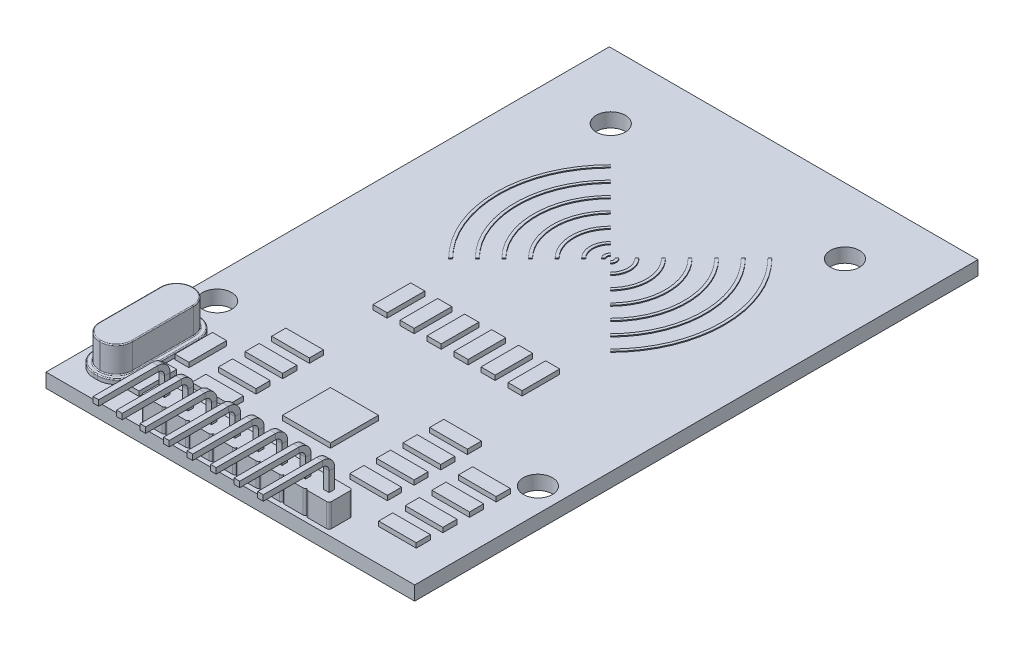
from build123d import *

# Parameters (mm, degrees)
SKETCH1_W                = 39.2
SKETCH1_H                = 59.9
BOSS_EXTRUDE1_DEPTH      = 1.5
SKETCH3_R                = 1.55
CUT_EXTRUDE1_DEPTH       = 1.5
BOSS_EXTRUDE3_DEPTH      = 2.5
SKETCH5_W                = 0.6
SKETCH5_H                = 0.6
CUT_EXTRUDE2_DEPTH       = 4
SKETCH6_W                = 0.6
SKETCH6_H                = 0.6
BOSS_EXTRUDE4_DEPTH      = 0.5
BOSS_EXTRUDE5_DEPTH      = 2.8
FILLET1_R                = 0.1
BOSS_EXTRUDE6_DEPTH      = 0.1
ESBO_O1_W                = 1.5
ESBO_O1_H                = 4
ESBO_O1_W_2              = 4
ESBO_O1_H_2              = 1.5
RESSALTO_EXTRUS_O1_DEPTH = 0.5
ESBO_O2_W                = 5.1
ESBO_O2_H                = 5.1
RESSALTO_EXTRUS_O2_DEPTH = 0.5


with BuildPart() as part:
    # Sketch1 → Boss-Extrude1 (new body)
    with BuildSketch(Plane(origin=(0, 0, 0), x_dir=(1, 0, 0), z_dir=(0, 1, 0))):
        Rectangle(SKETCH1_W, SKETCH1_H)
    extrude(amount=BOSS_EXTRUDE1_DEPTH)

    # Sketch3 → Cut-Extrude1 (cut)
    with BuildSketch(Plane(origin=(0, 1.5, 0), x_dir=(1, 0, 0), z_dir=(0, 1, 0))):
        with Locations((12.45, 22.95)):
            Circle(SKETCH3_R)
        with Locations((-12.45, 22.95)):
            Circle(SKETCH3_R)
        with Locations((17.05, -14.3)):
            Circle(SKETCH3_R)
        with Locations((-17.05, -14.3)):
            Circle(SKETCH3_R)
    extrude(amount=-CUT_EXTRUDE1_DEPTH, mode=Mode.SUBTRACT)

    # Sketch4 → Boss-Extrude3 (add)
    with BuildSketch(Plane(origin=(0, 1.5, 0), x_dir=(1, 0, 0), z_dir=(0, 1, 0))):
        with BuildLine():
            Line((-9.75, -26.95), (-7.75, -26.95))
            ThreePointArc((-7.75, -26.95), (-7.573223305, -27.023223305), (-7.5, -27.2))
            ThreePointArc((-7.5, -27.2), (-7.426776695, -27.023223305), (-7.25, -26.95))
            Line((-7.25, -26.95), (-5.25, -26.95))
            ThreePointArc((-5.25, -26.95), (-5.073223305, -27.023223305), (-5, -27.2))
            ThreePointArc((-5, -27.2), (-4.926776695, -27.023223305), (-4.75, -26.95))
            Line((-4.75, -26.95), (-2.75, -26.95))
            ThreePointArc((-2.75, -26.95), (-2.573223305, -27.023223305), (-2.5, -27.2))
            ThreePointArc((-2.5, -27.2), (-2.426776695, -27.023223305), (-2.25, -26.95))
            Line((-2.25, -26.95), (-0.25, -26.95))
            ThreePointArc((-0.25, -26.95), (-0.073223305, -27.023223305), (0, -27.2))
            ThreePointArc((0, -27.2), (0.073223305, -27.023223305), (0.25, -26.95))
            Line((0.25, -26.95), (2.25, -26.95))
            ThreePointArc((2.25, -26.95), (2.426776695, -27.023223305), (2.5, -27.2))
            ThreePointArc((2.5, -27.2), (2.573223305, -27.023223305), (2.75, -26.95))
            Line((2.75, -26.95), (4.75, -26.95))
            ThreePointArc((4.75, -26.95), (4.926776695, -27.023223305), (5, -27.2))
            ThreePointArc((5, -27.2), (5.073223305, -27.023223305), (5.25, -26.95))
            Line((5.25, -26.95), (7.25, -26.95))
            ThreePointArc((7.25, -26.95), (7.426776695, -27.023223305), (7.5, -27.2))
            ThreePointArc((7.5, -27.2), (7.573223305, -27.023223305), (7.75, -26.95))
            Line((7.75, -26.95), (9.75, -26.95))
            ThreePointArc((9.75, -26.95), (9.926776695, -27.023223305), (10, -27.2))
            Line((10, -27.2), (10, -29.2))
            ThreePointArc((10, -29.2), (9.926776695, -29.376776695), (9.75, -29.45))
            Line((9.75, -29.45), (7.75, -29.45))
            ThreePointArc((7.75, -29.45), (7.573223305, -29.376776695), (7.5, -29.2))
            ThreePointArc((7.5, -29.2), (7.426776695, -29.376776695), (7.25, -29.45))
            Line((7.25, -29.45), (5.25, -29.45))
            ThreePointArc((5.25, -29.45), (5.073223305, -29.376776695), (5, -29.2))
            ThreePointArc((5, -29.2), (4.926776695, -29.376776695), (4.75, -29.45))
            Line((4.75, -29.45), (2.75, -29.45))
            ThreePointArc((2.75, -29.45), (2.573223305, -29.376776695), (2.5, -29.2))
            ThreePointArc((2.5, -29.2), (2.426776695, -29.376776695), (2.25, -29.45))
            Line((2.25, -29.45), (0.25, -29.45))
            ThreePointArc((0.25, -29.45), (0.073223305, -29.376776695), (0, -29.2))
            ThreePointArc((0, -29.2), (-0.073223305, -29.376776695), (-0.25, -29.45))
            Line((-0.25, -29.45), (-2.25, -29.45))
            ThreePointArc((-2.25, -29.45), (-2.426776695, -29.376776695), (-2.5, -29.2))
            ThreePointArc((-2.5, -29.2), (-2.573223305, -29.376776695), (-2.75, -29.45))
            Line((-2.75, -29.45), (-4.75, -29.45))
            ThreePointArc((-4.75, -29.45), (-4.926776695, -29.376776695), (-5, -29.2))
            ThreePointArc((-5, -29.2), (-5.073223305, -29.376776695), (-5.25, -29.45))
            Line((-5.25, -29.45), (-7.25, -29.45))
            ThreePointArc((-7.25, -29.45), (-7.426776695, -29.376776695), (-7.5, -29.2))
            ThreePointArc((-7.5, -29.2), (-7.573223305, -29.376776695), (-7.75, -29.45))
            Line((-7.75, -29.45), (-9.75, -29.45))
            ThreePointArc((-9.75, -29.45), (-9.926776695, -29.376776695), (-10, -29.2))
            Line((-10, -29.2), (-10, -27.2))
            ThreePointArc((-10, -27.2), (-9.926776695, -27.023223305), (-9.75, -26.95))
        make_face()
    extrude(amount=BOSS_EXTRUDE3_DEPTH)

    # Sketch5 → Cut-Extrude2 (cut)
    with BuildSketch(Plane(origin=(0, 4, 0), x_dir=(1, 0, 0), z_dir=(0, 1, 0))):
        with Locations((-8.75, -28.2)):
            Rectangle(SKETCH5_W, SKETCH5_H)
        with Locations((-6.25, -28.2)):
            Rectangle(SKETCH5_W, SKETCH5_H)
        with Locations((-3.75, -28.2)):
            Rectangle(SKETCH5_W, SKETCH5_H)
        with Locations((-1.25, -28.2)):
            Rectangle(SKETCH5_W, SKETCH5_H)
        with Locations((1.25, -28.2)):
            Rectangle(SKETCH5_W, SKETCH5_H)
        with Locations((3.75, -28.2)):
            Rectangle(SKETCH5_W, SKETCH5_H)
        with Locations((6.25, -28.2)):
            Rectangle(SKETCH5_W, SKETCH5_H)
        with Locations((8.75, -28.2)):
            Rectangle(SKETCH5_W, SKETCH5_H)
    extrude(amount=-CUT_EXTRUDE2_DEPTH, mode=Mode.SUBTRACT)

    # Sweep1: sweep along a path in Sketch7
    with BuildLine(Plane.ZY.offset(10)) as sweep1_path:
        Line((28.2, -1), (28.2, 6))
        ThreePointArc((28.2, 6), (28.492893219, 6.707106781), (29.2, 7))
        Line((29.2, 7), (35.5, 7))
    # Sketch6 → Sweep1 (sweep)
    with BuildSketch(Plane(origin=(0, -1, 0), x_dir=(-1, 0, 0), z_dir=(0, -1, 0))):
        with Locations((6.25, -28.2)):
            Rectangle(SKETCH6_W, SKETCH6_H)
        with Locations((8.75, -28.2)):
            Rectangle(SKETCH6_W, SKETCH6_H)
        with Locations((3.75, -28.2)):
            Rectangle(SKETCH6_W, SKETCH6_H)
        with Locations((1.25, -28.2)):
            Rectangle(SKETCH6_W, SKETCH6_H)
        with Locations((-1.25, -28.2)):
            Rectangle(SKETCH6_W, SKETCH6_H)
        with Locations((-3.75, -28.2)):
            Rectangle(SKETCH6_W, SKETCH6_H)
        with Locations((-6.25, -28.2)):
            Rectangle(SKETCH6_W, SKETCH6_H)
        with Locations((-8.75, -28.2)):
            Rectangle(SKETCH6_W, SKETCH6_H)
    sweep(path=sweep1_path.line)

    # Sketch8 → Boss-Extrude4 (add)
    with BuildSketch(Plane(origin=(0, 1.5, 0), x_dir=(1, 0, 0), z_dir=(0, 1, 0))):
        with BuildLine():
            Line((-16.5, -17.15), (-16.15, -17.15))
            ThreePointArc((-16.15, -17.15), (-14.66507576, -17.76507576), (-14.05, -19.25))
            Line((-14.05, -19.25), (-14.05, -25.85))
            ThreePointArc((-14.05, -25.85), (-14.66507576, -27.33492424), (-16.15, -27.95))
            Line((-16.15, -27.95), (-16.5, -27.95))
            ThreePointArc((-16.5, -27.95), (-17.98492424, -27.33492424), (-18.6, -25.85))
            Line((-18.6, -25.85), (-18.6, -19.25))
            ThreePointArc((-18.6, -19.25), (-17.98492424, -17.76507576), (-16.5, -17.15))
        make_face()
    extrude(amount=BOSS_EXTRUDE4_DEPTH)

    # Sketch10 → Boss-Extrude5 (add)
    with BuildSketch(Plane(origin=(0, 2, 0), x_dir=(1, 0, 0), z_dir=(0, 1, 0))):
        with BuildLine():
            Line((-16.375, -17.6), (-16.275, -17.6))
            ThreePointArc((-16.275, -17.6), (-15.072918472, -18.097918472), (-14.575, -19.3))
            Line((-14.575, -19.3), (-14.575, -25.8))
            ThreePointArc((-14.575, -25.8), (-15.072918472, -27.002081528), (-16.275, -27.5))
            Line((-16.275, -27.5), (-16.375, -27.5))
            ThreePointArc((-16.375, -27.5), (-17.577081528, -27.002081528), (-18.075, -25.8))
            Line((-18.075, -25.8), (-18.075, -19.3))
            ThreePointArc((-18.075, -19.3), (-17.577081528, -18.097918472), (-16.375, -17.6))
        make_face()
    extrude(amount=BOSS_EXTRUDE5_DEPTH)

    # Fillet1
    fillet1_edges = [part.edges().sort_by_distance(p)[0] for p in [
        (-17.98492424, 2, 27.33492424),
        (-16.325, 2, 27.95),
        (-14.66507576, 2, 27.33492424),
        (-14.05, 2, 22.55),
        (-14.66507576, 2, 17.76507576),
        (-16.325, 2, 17.15),
        (-17.98492424, 2, 17.76507576),
        (-18.6, 2, 22.55),
        (-17.577081528, 2, 27.002081528),
        (-16.325, 2, 27.5),
        (-15.072918472, 2, 27.002081528),
        (-14.575, 2, 22.55),
        (-15.072918472, 2, 18.097918472),
        (-16.325, 2, 17.6),
        (-17.577081528, 2, 18.097918472),
        (-18.075, 2, 22.55),
        (-17.577081528, 4.8, 27.002081528),
        (-16.325, 4.8, 27.5),
        (-15.072918472, 4.8, 27.002081528),
        (-14.575, 4.8, 22.55),
        (-15.072918472, 4.8, 18.097918472),
        (-16.325, 4.8, 17.6),
        (-17.577081528, 4.8, 18.097918472),
        (-18.075, 4.8, 22.55),
    ]]
    fillet(fillet1_edges, radius=FILLET1_R)

    # Sketch11 → Boss-Extrude6 (add)
    with BuildSketch(Plane(origin=(0, 1.5, 0), x_dir=(1, 0, 0), z_dir=(0, 1, 0))):
        with BuildLine():
            Line((-0.247487373, 10.697487373), (-0.459619408, 10.909619408))
            ThreePointArc((-0.459619408, 10.909619408), (-0.65, 10.45), (-0.459619408, 9.990380592))
            Line((-0.459619408, 9.990380592), (-0.247487373, 10.202512627))
            ThreePointArc((-0.247487373, 10.202512627), (-0.35, 10.45), (-0.247487373, 10.697487373))
        make_face()
        with BuildLine():
            Line((0.247487373, 10.697487373), (0.459619408, 10.909619408))
            ThreePointArc((0.459619408, 10.909619408), (0.65, 10.45), (0.459619408, 9.990380592))
            Line((0.459619408, 9.990380592), (0.247487373, 10.202512627))
            ThreePointArc((0.247487373, 10.202512627), (0.35, 10.45), (0.247487373, 10.697487373))
        make_face()
        with BuildLine():
            Line((-8.485281374, 18.935281374), (-8.591347391, 19.041347391))
            ThreePointArc((-8.591347391, 19.041347391), (-12.15, 10.45), (-8.591347391, 1.858652609))
            Line((-8.591347391, 1.858652609), (-8.485281374, 1.964718626))
            Line((-8.485281374, 1.964718626), (-8.379215357, 2.070784643))
            ThreePointArc((-8.379215357, 2.070784643), (-11.85, 10.45), (-8.379215357, 18.829215357))
            Line((-8.379215357, 18.829215357), (-8.485281374, 18.935281374))
        make_face()
        with BuildLine():
            Line((8.485281374, 1.964718626), (8.591347391, 1.858652609))
            ThreePointArc((8.591347391, 1.858652609), (12.15, 10.45), (8.591347391, 19.041347391))
            Line((8.591347391, 19.041347391), (8.485281374, 18.935281374))
            Line((8.485281374, 18.935281374), (8.379215357, 18.829215357))
            ThreePointArc((8.379215357, 18.829215357), (11.85, 10.45), (8.379215357, 2.070784643))
            Line((8.379215357, 2.070784643), (8.485281374, 1.964718626))
        make_face()
        with BuildLine():
            Line((-6.965001795, 17.415001795), (-7.177133829, 17.627133829))
            ThreePointArc((-7.177133829, 17.627133829), (-10.15, 10.45), (-7.177133829, 3.272866171))
            Line((-7.177133829, 3.272866171), (-6.965001795, 3.484998205))
            ThreePointArc((-6.965001795, 3.484998205), (-9.85, 10.45), (-6.965001795, 17.415001795))
        make_face()
        with BuildLine():
            Line((-5.550788232, 16.000788232), (-5.762920267, 16.212920267))
            ThreePointArc((-5.762920267, 16.212920267), (-8.15, 10.45), (-5.762920267, 4.687079733))
            Line((-5.762920267, 4.687079733), (-5.550788232, 4.899211768))
            ThreePointArc((-5.550788232, 4.899211768), (-7.85, 10.45), (-5.550788232, 16.000788232))
        make_face()
        with BuildLine():
            Line((-4.13657467, 14.58657467), (-4.348706704, 14.798706704))
            ThreePointArc((-4.348706704, 14.798706704), (-6.15, 10.45), (-4.348706704, 6.101293296))
            Line((-4.348706704, 6.101293296), (-4.13657467, 6.31342533))
            ThreePointArc((-4.13657467, 6.31342533), (-5.85, 10.45), (-4.13657467, 14.58657467))
        make_face()
        with BuildLine():
            Line((-2.722361108, 13.172361108), (-2.934493142, 13.384493142))
            ThreePointArc((-2.934493142, 13.384493142), (-4.15, 10.45), (-2.934493142, 7.515506858))
            Line((-2.934493142, 7.515506858), (-2.722361108, 7.727638892))
            ThreePointArc((-2.722361108, 7.727638892), (-3.85, 10.45), (-2.722361108, 13.172361108))
        make_face()
        with BuildLine():
            Line((-1.308147545, 11.758147545), (-1.52027958, 11.97027958))
            ThreePointArc((-1.52027958, 11.97027958), (-2.15, 10.45), (-1.52027958, 8.92972042))
            Line((-1.52027958, 8.92972042), (-1.308147545, 9.141852455))
            ThreePointArc((-1.308147545, 9.141852455), (-1.85, 10.45), (-1.308147545, 11.758147545))
        make_face()
        with BuildLine():
            Line((1.308147545, 9.141852455), (1.52027958, 8.92972042))
            ThreePointArc((1.52027958, 8.92972042), (2.15, 10.45), (1.52027958, 11.97027958))
            Line((1.52027958, 11.97027958), (1.308147545, 11.758147545))
            ThreePointArc((1.308147545, 11.758147545), (1.85, 10.45), (1.308147545, 9.141852455))
        make_face()
        with BuildLine():
            Line((2.722361108, 7.727638892), (2.934493142, 7.515506858))
            ThreePointArc((2.934493142, 7.515506858), (4.15, 10.45), (2.934493142, 13.384493142))
            Line((2.934493142, 13.384493142), (2.722361108, 13.172361108))
            ThreePointArc((2.722361108, 13.172361108), (3.85, 10.45), (2.722361108, 7.727638892))
        make_face()
        with BuildLine():
            Line((4.13657467, 6.31342533), (4.348706704, 6.101293296))
            ThreePointArc((4.348706704, 6.101293296), (6.15, 10.45), (4.348706704, 14.798706704))
            Line((4.348706704, 14.798706704), (4.13657467, 14.58657467))
            ThreePointArc((4.13657467, 14.58657467), (5.85, 10.45), (4.13657467, 6.31342533))
        make_face()
        with BuildLine():
            Line((5.550788232, 4.899211768), (5.762920267, 4.687079733))
            ThreePointArc((5.762920267, 4.687079733), (8.15, 10.45), (5.762920267, 16.212920267))
            Line((5.762920267, 16.212920267), (5.550788232, 16.000788232))
            ThreePointArc((5.550788232, 16.000788232), (7.85, 10.45), (5.550788232, 4.899211768))
        make_face()
        with BuildLine():
            Line((6.965001795, 3.484998205), (7.177133829, 3.272866171))
            ThreePointArc((7.177133829, 3.272866171), (10.15, 10.45), (7.177133829, 17.627133829))
            Line((7.177133829, 17.627133829), (6.965001795, 17.415001795))
            ThreePointArc((6.965001795, 17.415001795), (9.85, 10.45), (6.965001795, 3.484998205))
        make_face()
    extrude(amount=BOSS_EXTRUDE6_DEPTH)

    # Esboço1 → Ressalto-extrusão1 (add)
    with BuildSketch(Plane(origin=(0, 1.5, 0), x_dir=(1, 0, 0), z_dir=(0, 1, 0))):
        with Locations((7.175, -4.85)):
            Rectangle(ESBO_O1_W, ESBO_O1_H)
        with Locations((4.305, -4.85)):
            Rectangle(ESBO_O1_W, ESBO_O1_H)
        with Locations((1.435, -4.85)):
            Rectangle(ESBO_O1_W, ESBO_O1_H)
        with Locations((-1.435, -4.85)):
            Rectangle(ESBO_O1_W, ESBO_O1_H)
        with Locations((-4.305, -4.85)):
            Rectangle(ESBO_O1_W, ESBO_O1_H)
        with Locations((-7.175, -4.85)):
            Rectangle(ESBO_O1_W, ESBO_O1_H)
        with Locations((-8.4, -22.9)):
            Rectangle(ESBO_O1_W_2, ESBO_O1_H_2)
        with Locations((-8.4, -20.066666667)):
            Rectangle(ESBO_O1_W_2, ESBO_O1_H_2)
        with Locations((-8.4, -17.233333333)):
            Rectangle(ESBO_O1_W_2, ESBO_O1_H_2)
        with Locations((-8.4, -14.4)):
            Rectangle(ESBO_O1_W_2, ESBO_O1_H_2)
        with Locations((8.4, -14.4)):
            Rectangle(ESBO_O1_W_2, ESBO_O1_H_2)
        with Locations((8.4, -17.233333333)):
            Rectangle(ESBO_O1_W_2, ESBO_O1_H_2)
        with Locations((8.4, -20.066666667)):
            Rectangle(ESBO_O1_W_2, ESBO_O1_H_2)
        with Locations((8.4, -22.9)):
            Rectangle(ESBO_O1_W_2, ESBO_O1_H_2)
        with Locations((-13.15, -19.95)):
            Rectangle(ESBO_O1_W, ESBO_O1_H)
        with Locations((-13.15, -25.25)):
            Rectangle(ESBO_O1_W, ESBO_O1_H)
        with Locations((14.3, -17.233333333)):
            Rectangle(ESBO_O1_W_2, ESBO_O1_H_2)
        with Locations((14.3, -20.066666667)):
            Rectangle(ESBO_O1_W_2, ESBO_O1_H_2)
        with Locations((14.3, -22.9)):
            Rectangle(ESBO_O1_W_2, ESBO_O1_H_2)
        with Locations((14.3, -25.733333333)):
            Rectangle(ESBO_O1_W_2, ESBO_O1_H_2)
    extrude(amount=RESSALTO_EXTRUS_O1_DEPTH)

    # Esboço2 → Ressalto-extrusão2 (add)
    with BuildSketch(Plane(origin=(0, 1.5, 0), x_dir=(1, 0, 0), z_dir=(0, 1, 0))):
        with Locations((0, -19.3)):
            Rectangle(ESBO_O2_W, ESBO_O2_H)
    extrude(amount=RESSALTO_EXTRUS_O2_DEPTH)


solid = part.part
